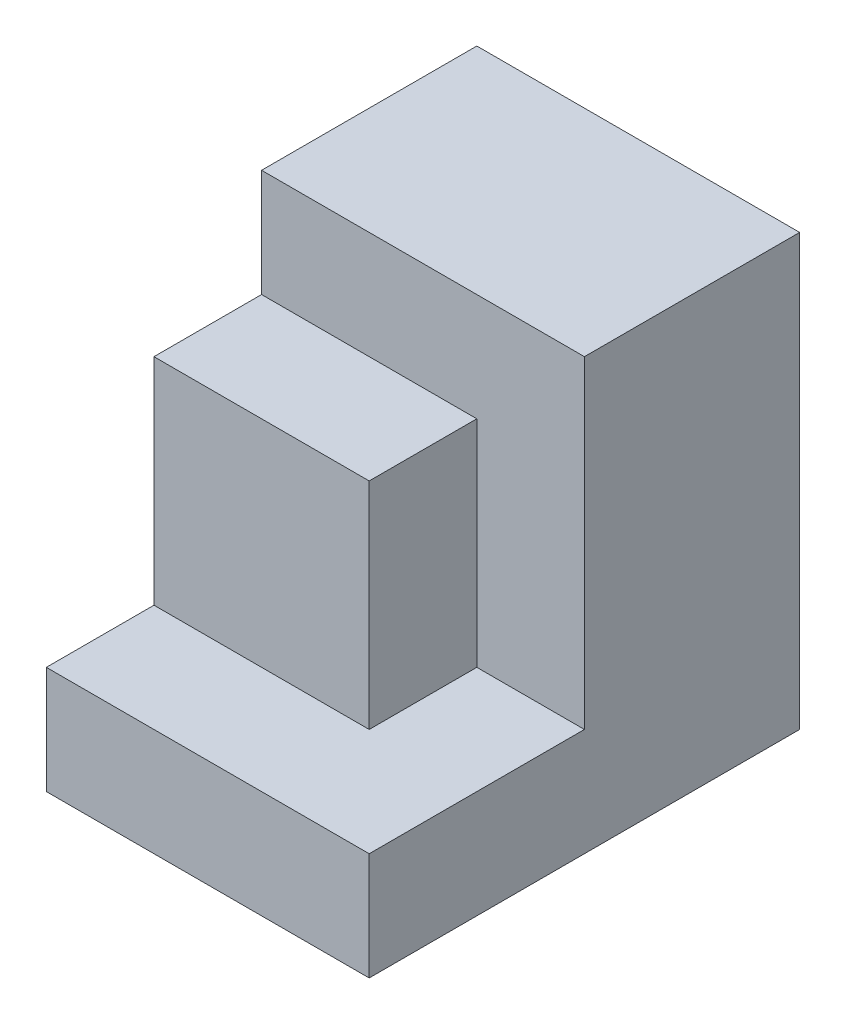
from build123d import *

# Parameters (mm, degrees)
SKETCH1_W           = 40
SKETCH1_H           = 40
BOSS_EXTRUDE1_DEPTH = 40
SKETCH2_W           = 10
SKETCH2_H           = 30
CUT_EXTRUDE1_DEPTH  = 40
SKETCH3_W           = 10
SKETCH3_H           = 10
CUT_EXTRUDE2_DEPTH  = 40
SKETCH4_W           = 30
SKETCH4_H           = 10
CUT_EXTRUDE3_DEPTH  = 30
SKETCH5_W           = 10
SKETCH5_H           = 10
CUT_EXTRUDE4_DEPTH  = 30
SKETCH6_W           = 20
SKETCH6_H           = 10
CUT_EXTRUDE6_DEPTH  = 10


with BuildPart() as part:
    # Sketch1 → Boss-Extrude1 (new body)
    with BuildSketch(Plane.XY):
        with Locations((20, 20)):
            Rectangle(SKETCH1_W, SKETCH1_H)
    extrude(amount=BOSS_EXTRUDE1_DEPTH)

    # Sketch2 → Cut-Extrude1 (cut)
    with BuildSketch(Plane.XY.offset(40)):
        with Locations((5, 25)):
            Rectangle(SKETCH2_W, SKETCH2_H)
        Polygon((0, 0), (10, 10), (0, 10), align=None)
    extrude(amount=-CUT_EXTRUDE1_DEPTH, mode=Mode.SUBTRACT)

    # Sketch3 → Cut-Extrude2 (cut)
    with BuildSketch(Plane.XZ):
        with Locations((5, 5)):
            Rectangle(SKETCH3_W, SKETCH3_H)
        with Locations((5, 35)):
            Rectangle(SKETCH3_W, SKETCH3_H)
    extrude(amount=-CUT_EXTRUDE2_DEPTH, mode=Mode.SUBTRACT)

    # Sketch4 → Cut-Extrude3 (cut)
    with BuildSketch(Plane(origin=(0, 40, 0), x_dir=(1, 0, 0), z_dir=(0, 1, 0))):
        with Locations((25, -35)):
            Rectangle(SKETCH4_W, SKETCH4_H)
    extrude(amount=-CUT_EXTRUDE3_DEPTH, mode=Mode.SUBTRACT)

    # Sketch5 → Cut-Extrude4 (cut)
    with BuildSketch(Plane(origin=(0, 40, 0), x_dir=(1, 0, 0), z_dir=(0, 1, 0))):
        with Locations((35, -25)):
            Rectangle(SKETCH5_W, SKETCH5_H)
    extrude(amount=-CUT_EXTRUDE4_DEPTH, mode=Mode.SUBTRACT)

    # Sketch6 → Cut-Extrude6 (cut)
    with BuildSketch(Plane.XY.offset(30)):
        with Locations((20, 35)):
            Rectangle(SKETCH6_W, SKETCH6_H)
    extrude(amount=-CUT_EXTRUDE6_DEPTH, mode=Mode.SUBTRACT)


solid = part.part
